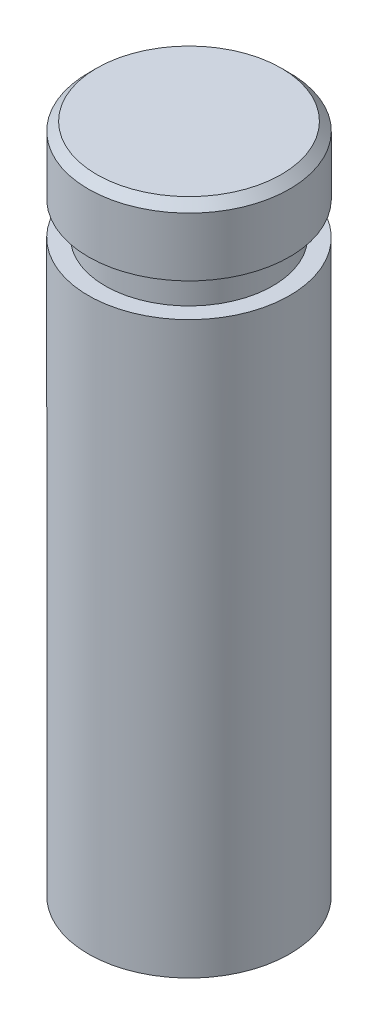
from build123d import *

# Parameters (mm, degrees)
ESBO_O1_R             = 6
EXTRUS_O1_DEPTH       = 40
ESBO_O2_R             = 5
CORTE_EXTRUS_O1_DEPTH = 30
CHANFRO1_SIZE         = 0.5
ESBO_O3_W             = 3
ESBO_O3_H             = 2


with BuildPart() as part:
    # Esboço1 → Extrusão1 (new body)
    with BuildSketch(Plane(origin=(0, 0, 0), x_dir=(1, 0, 0), z_dir=(0, 1, 0))):
        with Locations(Location((0, 0, 0), (0, 0, 270))):  # turned: the seam where the file's is
            Circle(ESBO_O1_R)
    extrude(amount=EXTRUS_O1_DEPTH)

    # Esboço2 → Corte-extrusão1 (cut)
    with BuildSketch(Plane.XZ):
        with Locations(Location((0, 0, 0), (0, 0, 270))):  # turned: the seam where the file's is
            Circle(ESBO_O2_R)
    extrude(amount=-CORTE_EXTRUS_O1_DEPTH, mode=Mode.SUBTRACT)

    # Chanfro1
    chanfro1_edges = [part.edges().sort_by_distance(p)[0] for p in [
        (0, 40, -6),
    ]]
    chamfer(chanfro1_edges, length=CHANFRO1_SIZE)

    # Esboço3 → Corte-Revolução3 (revolve, cut)
    with BuildSketch(Plane.XY, mode=Mode.PRIVATE) as corte_revolu_o3_sk:
        with Locations((6.5, 35)):
            Rectangle(ESBO_O3_W, ESBO_O3_H)
    revolve(corte_revolu_o3_sk.sketch.rotate(Axis((0, 0, 0), (0, 1, 0)), 90), axis=Axis((0, 0, 0), (0, 1, 0)), mode=Mode.SUBTRACT)  # turned: the seam where the file's is


solid = part.part
